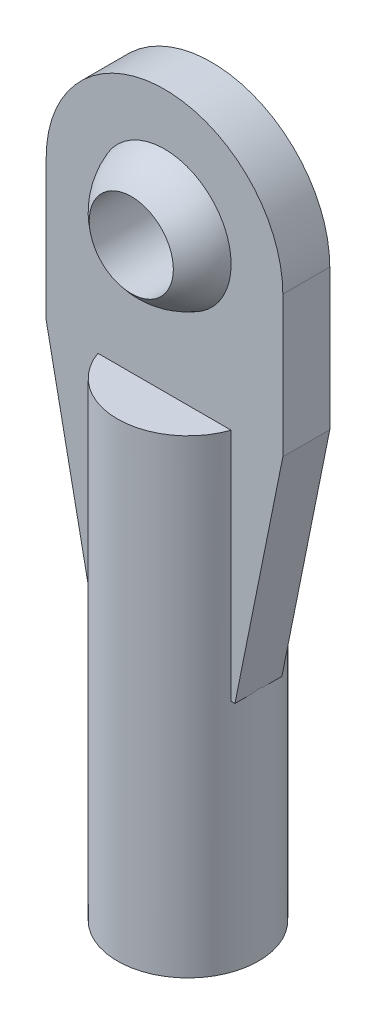
from build123d import *

# Parameters (mm, degrees)
SKETCH3_R                 = 1.4224
CUT_EXTRUDE1_DEPTH        = 3.3876
CUT_EXTRUDE1_DEPTH_BACK   = 3.3876
SKETCH4_R                 = 1.4224
BOSS_EXTRUDE1_DEPTH       = 0.79375
SKETCH5_R                 = 2.3876
BOSS_EXTRUDE2_DEPTH       = 7.9375
F_4_40_TAPPED_HOLE1_D     = 2.2606
F_4_40_TAPPED_HOLE1_DEPTH = 12.7
F_4_40_TAPPED_HOLE1_TIP   = 0.679152758


with BuildPart() as part:
    # Sketch2 → Revolve1 (revolve)
    with BuildSketch(Plane.XY):
        with BuildLine():
            Line((0, 2.3876), (0, -2.3876))
            ThreePointArc((0, -2.3876), (2.3876, 0), (0, 2.3876))
        make_face()
    revolve(axis=Axis((0, 6.043929029, 0), (0, -1, 0)))

    # Sketch3 → Cut-Extrude1 (cut, two sides)
    with BuildSketch(Plane.XY) as cut_extrude1_sk:
        Circle(SKETCH3_R)
    extrude(amount=CUT_EXTRUDE1_DEPTH, mode=Mode.SUBTRACT)
    extrude(cut_extrude1_sk.sketch, amount=-CUT_EXTRUDE1_DEPTH_BACK, mode=Mode.SUBTRACT)

    # Sketch4 → Boss-Extrude1 (add, symmetric)
    with BuildSketch(Plane.XY):
        with BuildLine():
            Line((-4.0005, 0), (-4.0005, -4.7625))
            Line((-4.0005, -4.7625), (-2.38125, -12.79525))
            Line((-2.38125, -12.79525), (2.38125, -12.79525))
            Line((2.38125, -12.79525), (4.0005, -4.7625))
            Line((4.0005, -4.7625), (4.0005, 0))
            ThreePointArc((4.0005, 0), (0, 4.0005), (-4.0005, 0))
        make_face()
        Circle(SKETCH4_R, mode=Mode.SUBTRACT)
    extrude(amount=BOSS_EXTRUDE1_DEPTH, both=True)

    # Sketch5 → Boss-Extrude2 (add, symmetric)
    with BuildSketch(Plane.XZ.offset(12.79525)):
        Circle(SKETCH5_R)
    extrude(amount=BOSS_EXTRUDE2_DEPTH, both=True)

    # #4-40 Tapped Hole1
    with Locations(Plane(origin=(0, -20.73275, 0), x_dir=(-1, 0, 0), z_dir=(0, -1, 0))):
        with Locations((0, 0)):
            Hole(F_4_40_TAPPED_HOLE1_D / 2, depth=F_4_40_TAPPED_HOLE1_DEPTH)
            with Locations((0, 0, -(F_4_40_TAPPED_HOLE1_DEPTH + F_4_40_TAPPED_HOLE1_TIP / 2))):  # 118° drill point
                Cone(0, F_4_40_TAPPED_HOLE1_D / 2, F_4_40_TAPPED_HOLE1_TIP, mode=Mode.SUBTRACT)


solid = part.part
